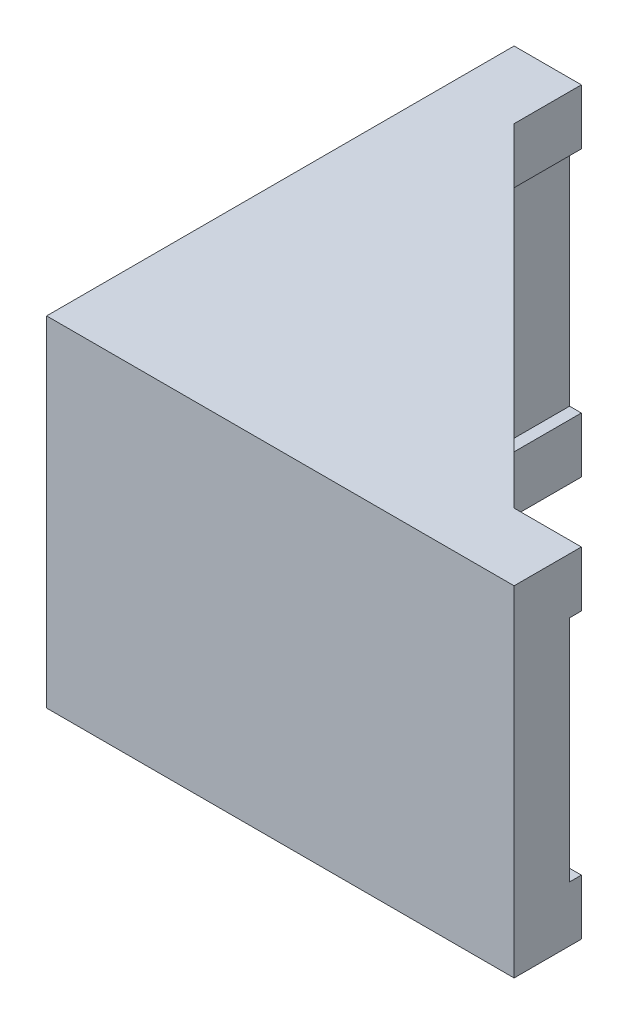
from build123d import *

# Parameters (mm, degrees)
BOSS_EXTRUDE1_DEPTH = 3.3
BOSS_EXTRUDE2_DEPTH = 13.6
BOSS_EXTRUDE3_DEPTH = 3.3


with BuildPart() as part:
    # Sketch1 → Boss-Extrude1 (new body)
    with BuildSketch(Plane(origin=(0, 0, 0), x_dir=(1, 0, 0), z_dir=(0, 1, 0))):
        Polygon((0, 0), (27.8, 0), (27.8, 4), (23.8, 4), (4, 23.8), (4, 27.8), (0, 27.8), align=None)
    extrude(amount=BOSS_EXTRUDE1_DEPTH)

    # Sketch2 → Boss-Extrude2 (add)
    with BuildSketch(Plane.XZ):
        Polygon((0, 0), (27.8, 0), (27.8, -3.3), (3.3, -3.3), (3.3, -27.8), (0, -27.8), align=None)
    extrude(amount=BOSS_EXTRUDE2_DEPTH)

    # Sketch3 → Boss-Extrude3 (add)
    with BuildSketch(Plane.XZ.offset(13.6)):
        Polygon((27.8, -3.3), (27.8, 0), (0, 0), (0, -27.8), (3.3, -27.8), (4, -27.8), (4, -23.8), (23.8, -4), (27.8, -4), align=None)
    extrude(amount=BOSS_EXTRUDE3_DEPTH)


solid = part.part
